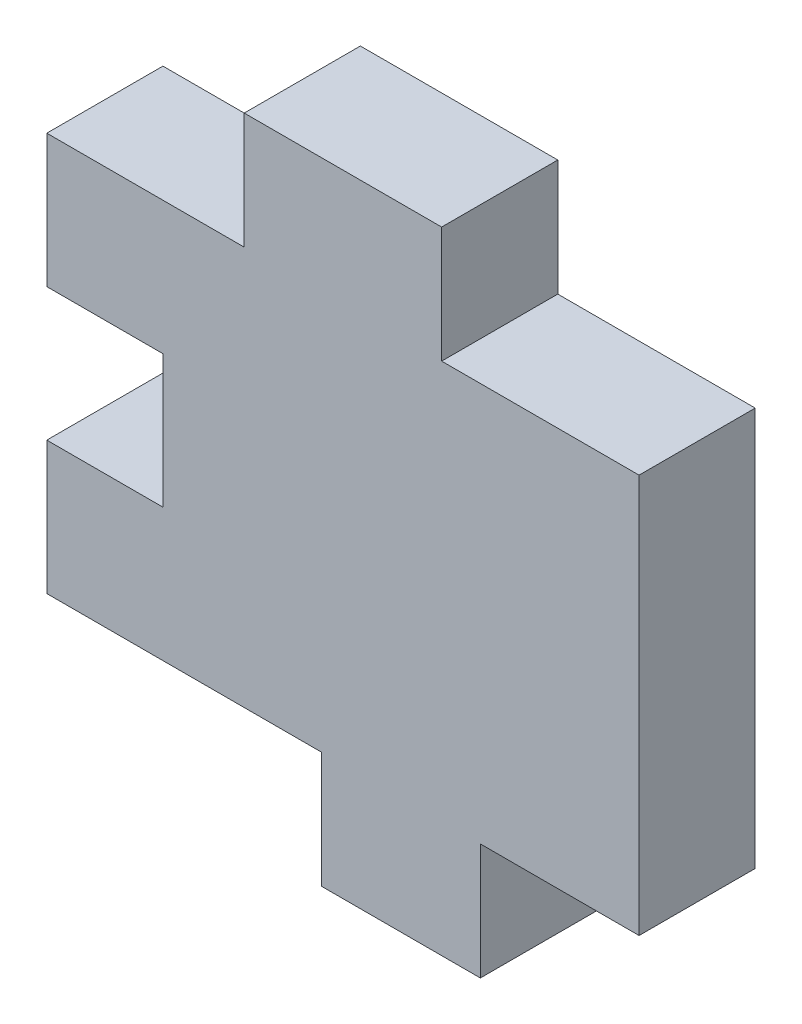
from build123d import *

# Parameters (mm, degrees)
BOSS_EXTRUDE1_DEPTH = 3


with BuildPart() as part:
    # Sketch1 → Boss-Extrude1 (new body)
    with BuildSketch(Plane.XY):
        Polygon((0, 0), (4.1, 0), (4.1, -3), (8.2, -3), (8.2, 0), (12.3, 0), (12.3, 10.3), (7.2, 10.3), (7.2, 13.3), (2.1, 13.3), (2.1, 10.3), (0, 10.3), (-3, 10.3), (-3, 6.866666667), (0, 6.866666667), (0, 3.433333333), (-3, 3.433333333), (-3, 0), align=None)
    extrude(amount=BOSS_EXTRUDE1_DEPTH)


solid = part.part
